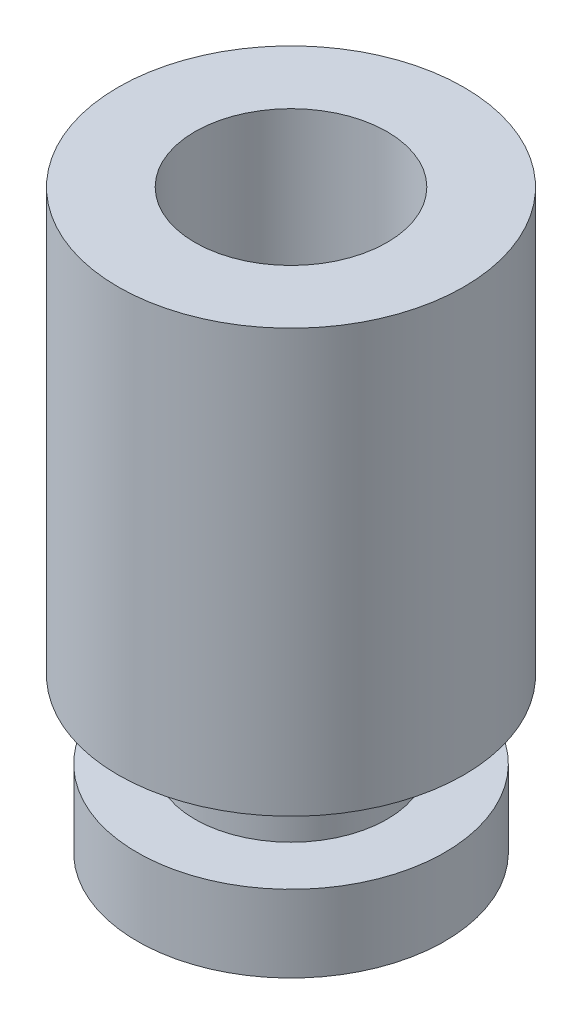
from build123d import *

# Parameters (mm, degrees)
SKETCH1_R           = 2.25
BOSS_EXTRUDE1_DEPTH = 5.5
SKETCH1_3_R         = 1.25
BOSS_EXTRUDE2_DEPTH = 1
SKETCH5_R           = 1.25
BOSS_EXTRUDE3_DEPTH = 1
SKETCH6_R           = 2
BOSS_EXTRUDE4_DEPTH = 1
SKETCH12_R          = 1.25
CUT_EXTRUDE1_DEPTH  = 5


with BuildPart() as part:
    # Sketch1 → Boss-Extrude1 (new body)
    with BuildSketch(Plane(origin=(0, 0, 0), x_dir=(1, 0, 0), z_dir=(0, 1, 0))):
        with Locations((-0.522013312, 0.511138034)):
            Circle(SKETCH1_R)
    extrude(amount=BOSS_EXTRUDE1_DEPTH)

    # Sketch1_3 → Boss-Extrude2 (add)
    with BuildSketch(Plane(origin=(0, 0, 0), x_dir=(1, 0, 0), z_dir=(0, 1, 0))):
        with Locations((-0.522013312, 0.511138034)):
            Circle(SKETCH1_3_R)
    extrude(amount=BOSS_EXTRUDE2_DEPTH)

    # Sketch5 → Boss-Extrude3 (add)
    with BuildSketch(Plane.XZ):
        with Locations((-0.522013312, -0.511138034)):
            Circle(SKETCH5_R)
    extrude(amount=BOSS_EXTRUDE3_DEPTH)

    # Sketch6 → Boss-Extrude4 (add)
    with BuildSketch(Plane.XZ.offset(1)):
        with Locations((-0.522013312, -0.511138034)):
            Circle(SKETCH6_R)
    extrude(amount=BOSS_EXTRUDE4_DEPTH)

    # Sketch12 → Cut-Extrude1 (cut)
    with BuildSketch(Plane(origin=(0, 5.5, 0), x_dir=(1, 0, 0), z_dir=(0, 1, 0))):
        with Locations((-0.522013312, 0.511138034)):
            Circle(SKETCH12_R)
    extrude(amount=-CUT_EXTRUDE1_DEPTH, mode=Mode.SUBTRACT)


solid = part.part
